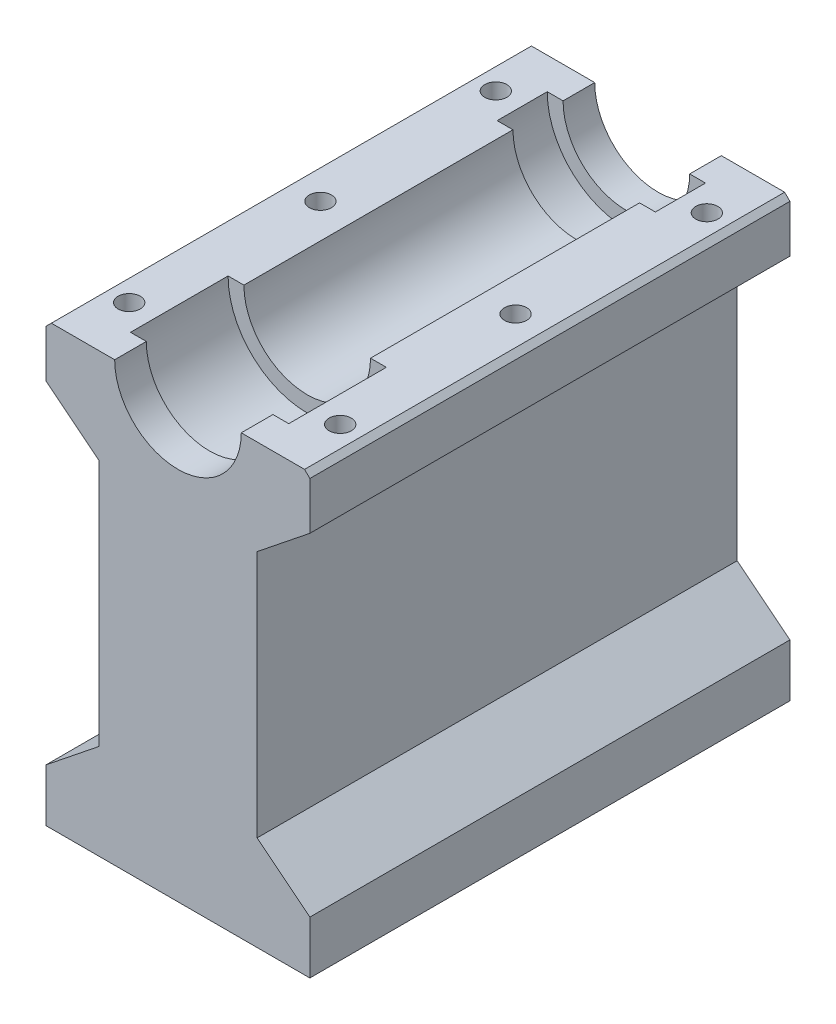
from build123d import *

# Parameters (mm, degrees)
BOSS_EXTRUDE1_DEPTH = 91
SKETCH8_W           = 3
SKETCH8_H           = 9.5
SKETCH8_H_2         = 18.5
M5X0_81_REACH       = 127.678
M5X0_81_BORE_R      = 2.1
BOSS_EXTRUDE2_DEPTH = 7
CHAMFER1_SIZE       = 0.5
CHAMFER_1_SIZE      = 1
M5X0_82_D           = 4.2
M5X0_82_DEPTH       = 17.4
M5X0_82_TIP         = 1.2618073


with BuildPart() as part:
    # Sketch1 → Boss-Extrude1 (new body)
    with BuildSketch(Plane.XY):
        with BuildLine():
            Line((12, 0), (25, 0))
            Line((25, 0), (25, -10))
            Line((25, -10), (15, -18))
            Line((15, -18), (15, -65))
            Line((15, -65), (25, -73))
            Line((25, -73), (25, -83))
            Line((25, -83), (-25, -83))
            Line((-25, -83), (-25, -73))
            Line((-25, -73), (-15, -65))
            Line((-15, -65), (-15, -18))
            Line((-15, -18), (-25, -10))
            Line((-25, -10), (-25, 0))
            Line((-25, 0), (-12, 0))
            ThreePointArc((-12, 0), (0, -12), (12, 0))
        make_face()
    extrude(amount=-BOSS_EXTRUDE1_DEPTH)

    # Sketch8 → Cut-Revolve2 (revolve, cut)
    with BuildSketch(Plane(origin=(0, 0, 0), x_dir=(1, 0, 0), z_dir=(0, 1, 0))):
        with Locations((13.5, 80.25)):
            Rectangle(SKETCH8_W, SKETCH8_H)
        with Locations((13.5, 15.25)):
            Rectangle(SKETCH8_W, SKETCH8_H_2)
    revolve(axis=Axis((0, 0, -91), (0, 0, 1)), mode=Mode.SUBTRACT)

    # Отверстие обработанное метчиком M5x0.81 bore → Отверстие обработанное метчиком M5x0.81 (cut, up to next)
    with BuildSketch(Plane(origin=(0, 0, 0), x_dir=(1, 0, 0), z_dir=(0, 1, 0)), mode=Mode.PRIVATE) as m5x0_81_sk1:
        with Locations((-20, 10.75)):
            Circle(M5X0_81_BORE_R)
    m5x0_81_tool1 = extrude(m5x0_81_sk1.sketch, amount=-M5X0_81_REACH, mode=Mode.PRIVATE) & part.part
    # Отверстие обработанное метчиком M5x0.81 bore → Отверстие обработанное метчиком M5x0.81 (cut, up to next)
    with BuildSketch(Plane(origin=(0, 0, 0), x_dir=(1, 0, 0), z_dir=(0, 1, 0)), mode=Mode.PRIVATE) as m5x0_81_sk2:
        with Locations((20, 10.75)):
            Circle(M5X0_81_BORE_R)
    m5x0_81_tool2 = extrude(m5x0_81_sk2.sketch, amount=-M5X0_81_REACH, mode=Mode.PRIVATE) & part.part
    # Отверстие обработанное метчиком M5x0.81 bore → Отверстие обработанное метчиком M5x0.81 (cut, up to next)
    with BuildSketch(Plane(origin=(0, 0, 0), x_dir=(1, 0, 0), z_dir=(0, 1, 0)), mode=Mode.PRIVATE) as m5x0_81_sk3:
        with Locations((-20, 80.25)):
            Circle(M5X0_81_BORE_R)
    m5x0_81_tool3 = extrude(m5x0_81_sk3.sketch, amount=-M5X0_81_REACH, mode=Mode.PRIVATE) & part.part
    # Отверстие обработанное метчиком M5x0.81 bore → Отверстие обработанное метчиком M5x0.81 (cut, up to next)
    with BuildSketch(Plane(origin=(0, 0, 0), x_dir=(1, 0, 0), z_dir=(0, 1, 0)), mode=Mode.PRIVATE) as m5x0_81_sk4:
        with Locations((20, 80.25)):
            Circle(M5X0_81_BORE_R)
    m5x0_81_tool4 = extrude(m5x0_81_sk4.sketch, amount=-M5X0_81_REACH, mode=Mode.PRIVATE) & part.part
    # Отверстие обработанное метчиком M5x0.81 bore → Отверстие обработанное метчиком M5x0.81 (cut, up to next)
    with BuildSketch(Plane(origin=(0, 0, 0), x_dir=(1, 0, 0), z_dir=(0, 1, 0)), mode=Mode.PRIVATE) as m5x0_81_sk5:
        with Locations((-18.5, 45.5)):
            Circle(M5X0_81_BORE_R)
    m5x0_81_tool5 = extrude(m5x0_81_sk5.sketch, amount=-M5X0_81_REACH, mode=Mode.PRIVATE) & part.part
    # Отверстие обработанное метчиком M5x0.81 bore → Отверстие обработанное метчиком M5x0.81 (cut, up to next)
    with BuildSketch(Plane(origin=(0, 0, 0), x_dir=(1, 0, 0), z_dir=(0, 1, 0)), mode=Mode.PRIVATE) as m5x0_81_sk6:
        with Locations((18.5, 45.5)):
            Circle(M5X0_81_BORE_R)
    m5x0_81_tool6 = extrude(m5x0_81_sk6.sketch, amount=-M5X0_81_REACH, mode=Mode.PRIVATE) & part.part
    add(m5x0_81_tool1.solids().sort_by_distance((-20, 0, -10.75))[0], mode=Mode.SUBTRACT)
    add(m5x0_81_tool2.solids().sort_by_distance((20, 0, -10.75))[0], mode=Mode.SUBTRACT)
    add(m5x0_81_tool3.solids().sort_by_distance((-20, 0, -80.25))[0], mode=Mode.SUBTRACT)
    add(m5x0_81_tool4.solids().sort_by_distance((20, 0, -80.25))[0], mode=Mode.SUBTRACT)
    add(m5x0_81_tool5.solids().sort_by_distance((-18.5, 0, -45.5))[0], mode=Mode.SUBTRACT)
    add(m5x0_81_tool6.solids().sort_by_distance((18.5, 0, -45.5))[0], mode=Mode.SUBTRACT)

    # Sketch9 → Boss-Extrude2 (add)
    with BuildSketch(Plane.XZ.offset(83)):
        with BuildLine():
            Line((-10, -25.225), (10, -25.225))
            ThreePointArc((10, -25.225), (12.475, -22.75), (10, -20.275))
            Line((10, -20.275), (-10, -20.275))
            ThreePointArc((-10, -20.275), (-12.475, -22.75), (-10, -25.225))
        make_face()
        with BuildLine():
            Line((-10, -65.775), (10, -65.775))
            ThreePointArc((10, -65.775), (12.475, -68.25), (10, -70.725))
            Line((10, -70.725), (-10, -70.725))
            ThreePointArc((-10, -70.725), (-12.475, -68.25), (-10, -65.775))
        make_face()
    extrude(amount=BOSS_EXTRUDE2_DEPTH)

    # Chamfer1
    chamfer1_edges = [part.edges().sort_by_distance(p)[0] for p in [
        (12.475, -90, -22.75),
        (0, -90, -20.275),
        (-12.475, -90, -22.75),
        (0, -90, -25.225),
        (12.475, -90, -68.25),
        (0, -90, -65.775),
        (-12.475, -90, -68.25),
        (0, -90, -70.725),
    ]]
    chamfer(chamfer1_edges, length=CHAMFER1_SIZE)

    # Фаска1
    chamfer_1_edges = [part.edges().sort_by_distance(p)[0] for p in [
        (-25, 0, -45.5),
        (25, 0, -45.5),
    ]]
    chamfer(chamfer_1_edges, length=CHAMFER_1_SIZE)

    # Отверстие обработанное метчиком M5x0.82
    with Locations(Plane(origin=(0, -83, 0), x_dir=(-1, 0, 0), z_dir=(0, -1, 0))):
        with Locations((0, 45.5), (0, 10.1375), (0, 80.8625)):
            Hole(M5X0_82_D / 2, depth=M5X0_82_DEPTH)
            with Locations((0, 0, -(M5X0_82_DEPTH + M5X0_82_TIP / 2))):  # 118° drill point
                Cone(0, M5X0_82_D / 2, M5X0_82_TIP, mode=Mode.SUBTRACT)


solid = part.part
